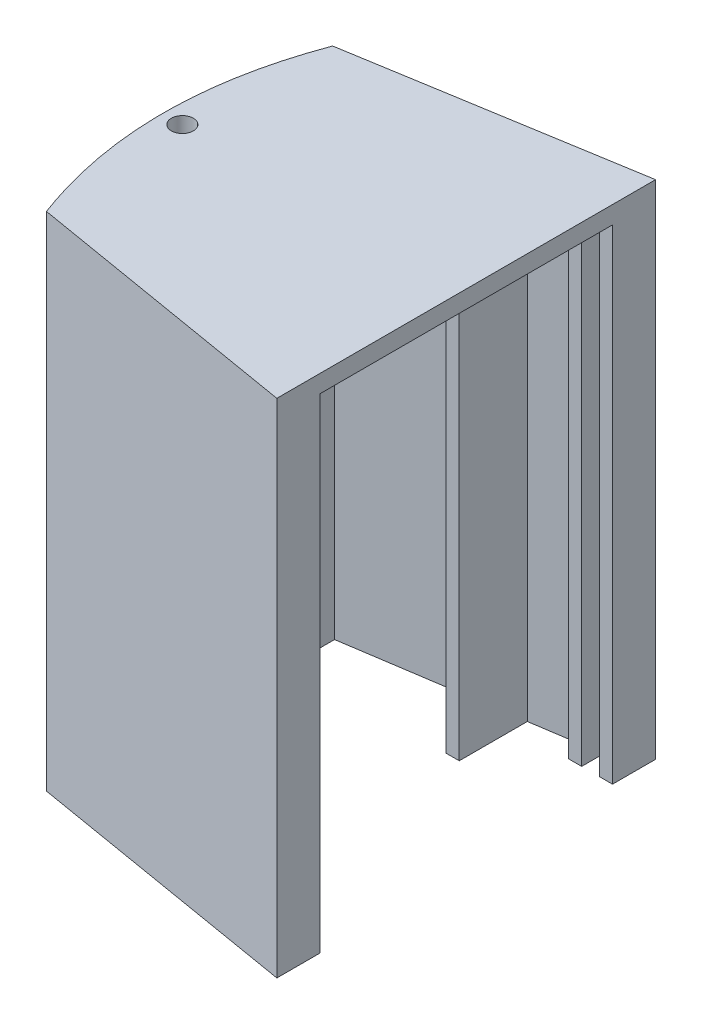
from build123d import *

# Parameters (mm, degrees)
SALIENTE_EXTRUIR11_DEPTH   = 110
SALIENTE_EXTRUIR12_DEPTH   = 4
CROQUIS7_R                 = 2.5
CORTAR_EXTRUIR2_DEPTH      = 1.0000001
CORTAR_EXTRUIR2_DEPTH_BACK = 115.0000001


with BuildPart() as part:
    # Croquis1 → Saliente-Extruir11 (new body)
    with BuildSketch(Plane(origin=(0, 0, 0), x_dir=(1, 0, 0), z_dir=(0, 1, 0))):
        with BuildLine():
            Line((27.20407189, 42.896490362), (27.20407189, 39.115188491))
            Line((27.20407189, 39.115188491), (27.20407189, 33.115188491))
            Line((27.20407189, 33.115188491), (24.20407189, 33.115188491))
            Line((24.20407189, 33.115188491), (24.20407189, 38.659429067))
            Line((24.20407189, 38.659429067), (20.20407189, 38.051749834))
            Line((20.20407189, 38.051749834), (20.20407189, 33.115188491))
            Line((20.20407189, 33.115188491), (17.20407189, 33.115188491))
            Line((17.20407189, 33.115188491), (17.20407189, 37.59599041))
            Line((17.20407189, 37.59599041), (5.20407189, 35.772952711))
            Line((5.20407189, 35.772952711), (5.20407189, 20.317193287))
            Line((5.20407189, 20.317193287), (2.20407189, 20.317193287))
            Line((2.20407189, 20.317193287), (2.20407189, 35.317193287))
            Line((2.20407189, 35.317193287), (-32.79592811, 30))
            Line((-32.79592811, 30), (-32.79592811, -30))
            Line((-32.79592811, -30), (2.20407189, -35.428420748))
            Line((2.20407189, -35.428420748), (2.20407189, -20.428420748))
            Line((2.20407189, -20.428420748), (5.20407189, -20.428420748))
            Line((5.20407189, -20.428420748), (5.20407189, -35.893713955))
            Line((5.20407189, -35.893713955), (17.20407189, -37.754886783))
            Line((17.20407189, -37.754886783), (17.20407189, -33.30586414))
            Line((17.20407189, -33.30586414), (20.20407189, -33.30586414))
            Line((20.20407189, -33.30586414), (20.20407189, -38.22017999))
            Line((20.20407189, -38.22017999), (24.20407189, -38.840570933))
            Line((24.20407189, -38.840570933), (24.20407189, -33.30586414))
            Line((24.20407189, -33.30586414), (27.20407189, -33.30586414))
            Line((27.20407189, -33.30586414), (27.20407189, -39.30586414))
            Line((27.20407189, -39.30586414), (27.20407189, -43.103509638))
            Line((27.20407189, -43.103509638), (-35.710171222, -32.509265277))
            add(Edge.make_bspline(
                [(-35.745382219, 32.513512597), (-47.864078296, -0.004370105), (-35.710171222, -32.509265277)],
                knots=[0, 0, 0, 1, 1, 1], degree=2))
            Line((-35.745382219, 32.513512597), (27.20407189, 42.896490362))
        make_face()
    extrude(amount=SALIENTE_EXTRUIR11_DEPTH)

    # Croquis6 → Saliente-Extruir12 (add)
    with BuildSketch(Plane(origin=(0, 110, 0), x_dir=(1, 0, 0), z_dir=(0, 1, 0))):
        with BuildLine():
            Line((-35.745382219, 32.513512597), (27.20407189, 42.896490362))
            Line((27.20407189, 42.896490362), (27.20407189, -43.103509638))
            Line((27.20407189, -43.103509638), (-35.710171222, -32.509265277))
            add(Edge.make_bspline(
                [(-35.745382219, 32.513512597), (-47.864078276, -0.004407917), (-35.710171222, -32.509265277)],
                knots=[0, 0, 0, 1, 1, 1], degree=2))
        make_face()
    extrude(amount=SALIENTE_EXTRUIR12_DEPTH)

    # Croquis7 → Cortar-Extruir2 (cut, two sides)
    with BuildSketch(Plane.XZ) as cortar_extruir2_sk:
        with Locations((-37.356797981, 0)):
            Circle(CROQUIS7_R)
    extrude(amount=CORTAR_EXTRUIR2_DEPTH, mode=Mode.SUBTRACT)
    extrude(cortar_extruir2_sk.sketch, amount=-CORTAR_EXTRUIR2_DEPTH_BACK, mode=Mode.SUBTRACT)


solid = part.part
